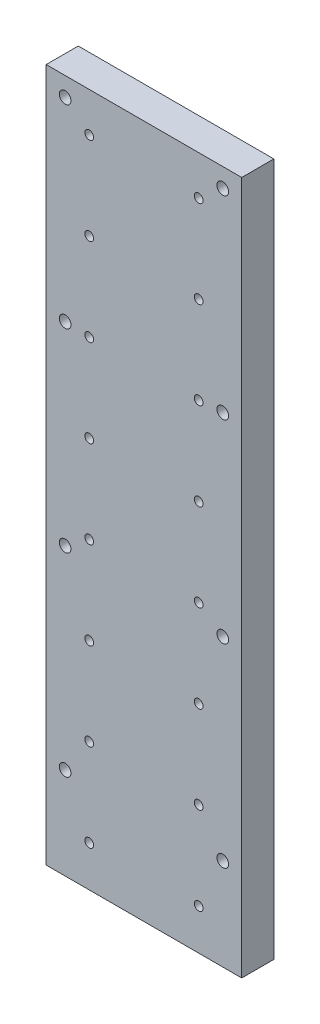
from build123d import *

# Parameters (mm, degrees)
SZKIC1_W                    = 134
SZKIC1_H                    = 475
DODANIE_WYCI_GNI_CIE1_DEPTH = 22
SZKIC2_R                    = 4
WYTNIJ_WYCI_GNI_CIE1_DEPTH  = 22
SZKIC4_R                    = 6.5
WYTNIJ_WYCI_GNI_CIE3_DEPTH  = 9
SZYK_LINIOWY3_COUNT         = 4
SZYK_LINIOWY3_PITCH         = 133
SZKIC5_R                    = 3
WYTNIJ_WYCI_GNI_CIE4_DEPTH  = 220
SZYK_LINIOWY5_COUNT         = 8
SZYK_LINIOWY5_PITCH         = 60
SZYK_LINIOWY5_COUNT_DIR2    = 2
SZYK_LINIOWY5_PITCH_DIR2    = 75


with BuildPart() as part:
    # Szkic1 → Dodanie-wyciągnięcie1 (new body)
    with BuildSketch(Plane.XY):
        Rectangle(SZKIC1_W, SZKIC1_H)
    extrude(amount=DODANIE_WYCI_GNI_CIE1_DEPTH)

    # Szkic2 → Wytnij-wyciągnięcie1 (cut)
    with BuildSketch(Plane.XY.offset(22)):
        with Locations((-54, 224.5)):
            Circle(SZKIC2_R)
        with Locations((54, 224.5)):
            Circle(SZKIC2_R)
    wytnij_wyci_gni_cie1 = extrude(amount=-WYTNIJ_WYCI_GNI_CIE1_DEPTH, mode=Mode.SUBTRACT)

    # Szkic4 → Wytnij-wyciągnięcie3 (cut)
    with BuildSketch(Plane(origin=(0, 0, 0), x_dir=(-1, 0, 0), z_dir=(0, 0, -1))):
        with Locations((-54, 224.5)):
            Circle(SZKIC4_R)
        with Locations((54, 224.5)):
            Circle(SZKIC4_R)
    wytnij_wyci_gni_cie3 = extrude(amount=-WYTNIJ_WYCI_GNI_CIE3_DEPTH, mode=Mode.SUBTRACT)

    # Szyk liniowy3: Wytnij-wyciągnięcie1, Wytnij-wyciągnięcie3 ×4
    with Locations(*[(0, -i * SZYK_LINIOWY3_PITCH, 0) for i in range(1, SZYK_LINIOWY3_COUNT)]):
        add(wytnij_wyci_gni_cie1, mode=Mode.SUBTRACT)
        add(wytnij_wyci_gni_cie3, mode=Mode.SUBTRACT)

    # Szkic5 → Wytnij-wyciągnięcie4 (cut)
    with BuildSketch(Plane(origin=(0, 0, 0), x_dir=(-1, 0, 0), z_dir=(0, 0, -1))):
        with Locations((37.5, 210.5)):
            Circle(SZKIC5_R)
    wytnij_wyci_gni_cie4 = extrude(amount=-WYTNIJ_WYCI_GNI_CIE4_DEPTH, mode=Mode.SUBTRACT)

    # Szyk liniowy5: Wytnij-wyci_gni_cie4 8 × 2
    with Locations(*[(j * SZYK_LINIOWY5_PITCH_DIR2, -i * SZYK_LINIOWY5_PITCH, 0) for i in range(SZYK_LINIOWY5_COUNT) for j in range(SZYK_LINIOWY5_COUNT_DIR2) if (i, j) != (0, 0)]):
        add(wytnij_wyci_gni_cie4, mode=Mode.SUBTRACT)


solid = part.part
